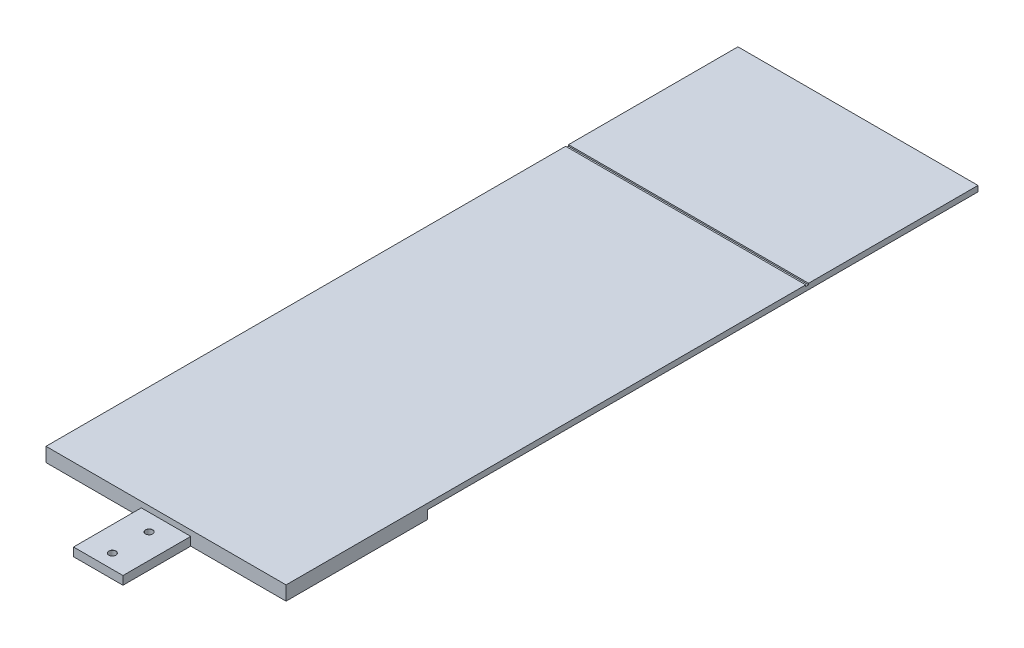
from build123d import *

# Parameters (mm, degrees)
BOSS_EXTRUDE1_DEPTH                  = 3
SKETCH10_W                           = 17.5
SKETCH10_H                           = 24
BOSS_EXTRUDE2_DEPTH                  = 3
F_2_5_2_5_DIAMETER_HOLE1_D           = 2.5
F_2_5_2_5_DIAMETER_HOLE1_DEPTH       = 6.35
F_2_5_2_5_DIAMETER_HOLE1_CSINK_D     = 2.55
F_2_5_2_5_DIAMETER_HOLE1_CSINK_ANGLE = 90
F_2_5_2_5_DIAMETER_HOLE1_TIP         = 0.751075774
CUT_EXTRUDE3_DEPTH                   = 4
SKETCH11_W                           = 85
SKETCH11_H                           = 245
BOSS_EXTRUDE3_DEPTH                  = 2
SKETCH12_W                           = 1
SKETCH12_H                           = 0.5
CUT_EXTRUDE4_DEPTH                   = 1
CUT_EXTRUDE4_DEPTH_BACK              = 86


with BuildPart() as part:
    # Sketch2 → Boss-Extrude1 (new body)
    with BuildSketch(Plane(origin=(0, 0, 0), x_dir=(1, 0, 0), z_dir=(0, 1, 0))):
        Polygon((42.5, 0), (42.5, 50), (22.5, 50), (8.75, 26.184301396), (-8.75, 26.184301396), (-22.5, 50), (-42.5, 50), (-42.5, 0), align=None)
    extrude(amount=BOSS_EXTRUDE1_DEPTH)

    # Sketch10 → Boss-Extrude2 (add)
    with BuildSketch(Plane(origin=(0, 3, 0), x_dir=(1, 0, 0), z_dir=(0, 1, 0))):
        with Locations((0, -12)):
            Rectangle(SKETCH10_W, SKETCH10_H)
    extrude(amount=-BOSS_EXTRUDE2_DEPTH)

    # Ø2.5 (2.5) Diameter Hole1
    with Locations(Plane(origin=(0, 3, 0), x_dir=(1, 0, 0), z_dir=(0, 1, 0))):
        with Locations((0, -19), (0, -6)):
            CounterSinkHole(F_2_5_2_5_DIAMETER_HOLE1_D / 2, F_2_5_2_5_DIAMETER_HOLE1_CSINK_D / 2, depth=F_2_5_2_5_DIAMETER_HOLE1_DEPTH, counter_sink_angle=F_2_5_2_5_DIAMETER_HOLE1_CSINK_ANGLE)
            with Locations((0, 0, -(F_2_5_2_5_DIAMETER_HOLE1_DEPTH + F_2_5_2_5_DIAMETER_HOLE1_TIP / 2))):  # 118° drill point
                Cone(0, F_2_5_2_5_DIAMETER_HOLE1_D / 2, F_2_5_2_5_DIAMETER_HOLE1_TIP, mode=Mode.SUBTRACT)

    # Sketch9 → Cut-Extrude3 (cut, through all)
    with BuildSketch(Plane.XZ):
        Polygon((-32, -50), (-25, -26.184301396), (25, -26.184301396), (32, -50), align=None)
    extrude(amount=-CUT_EXTRUDE3_DEPTH, mode=Mode.SUBTRACT)

    # Sketch11 → Boss-Extrude3 (add)
    with BuildSketch(Plane(origin=(0, 3, 0), x_dir=(1, 0, 0), z_dir=(0, 1, 0))):
        with Locations((0, 122.5)):
            Rectangle(SKETCH11_W, SKETCH11_H)
    extrude(amount=BOSS_EXTRUDE3_DEPTH)

    # Sketch12 → Cut-Extrude4 (cut, two sides)
    with BuildSketch(Plane.ZY.offset(42.5)) as cut_extrude4_sk:
        with Locations((-184.5, 4.75)):
            Rectangle(SKETCH12_W, SKETCH12_H)
    extrude(amount=CUT_EXTRUDE4_DEPTH, mode=Mode.SUBTRACT)
    extrude(cut_extrude4_sk.sketch, amount=-CUT_EXTRUDE4_DEPTH_BACK, mode=Mode.SUBTRACT)


solid = part.part
